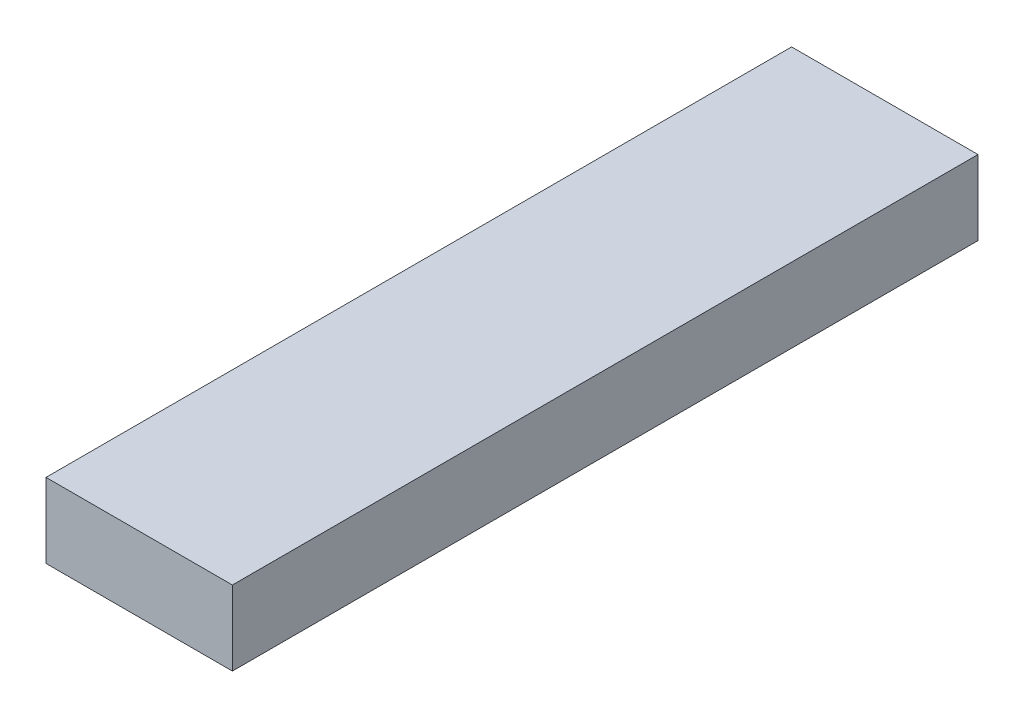
from build123d import *

# Parameters (mm, degrees)
SKETCH_1_W      = 50
SKETCH_1_H      = 200
EXTRUDE_1_DEPTH = 10


with BuildPart() as part:
    # 草图1 → 凸台-拉伸1 (new body, symmetric)
    with BuildSketch(Plane(origin=(0, 0, 0), x_dir=(1, 0, 0), z_dir=(0, 1, 0))):
        with Locations((25, -100)):
            Rectangle(SKETCH_1_W, SKETCH_1_H)
    extrude(amount=EXTRUDE_1_DEPTH, both=True)


solid = part.part
